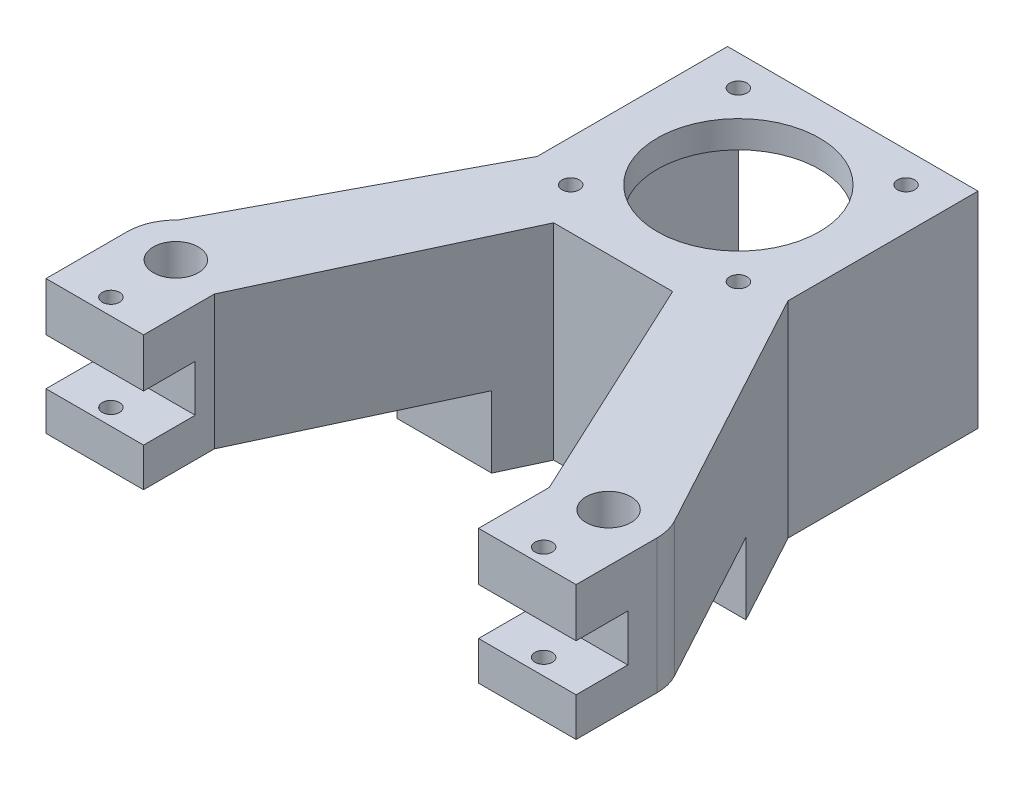
from build123d import *

# Parameters (mm, degrees)
SKETCH_6_W          = 42.3
SKETCH_6_H          = 42.3
SKETCH_6_R          = 1.6
SKETCH_6_R_2        = 15
EXTRUDE_1_DEPTH     = 5
SKETCH_7_R          = 1.6
SKETCH_7_R_2        = 4.15
EXTRUDE_5_DEPTH     = 38
SKETCH_7_7_R        = 4.15
SKETCH_7_7_R_2      = 1.6
EXTRUDE_7_DEPTH     = 38
SKETCH_7_8_R        = 4.15
SKETCH_7_8_R_2      = 1.6
EXTRUDE_8_DEPTH     = 38
SKETCH_12_W         = 2
SKETCH_12_H         = 44.3
EXTRUDE_11_DEPTH    = 38
SKETCH_14_W         = 44.3
SKETCH_14_H         = 2
EXTRUDE_12_DEPTH    = 38
SKETCH_15_W         = 2
SKETCH_15_H         = 42.3
EXTRUDE_13_DEPTH    = 38
CUT_EXTRUDE_1_DEPTH = 13.2
SKETCH_18_W         = 9.549489015
SKETCH_18_H         = 8.643215043
CUT_EXTRUDE_2_DEPTH = 123


with BuildPart() as part:
    # 草图6 → 凸台-拉伸1 (new body)
    with BuildSketch(Plane(origin=(0, 0, 0), x_dir=(1, 0, 0), z_dir=(0, 1, 0))):
        Rectangle(SKETCH_6_W, SKETCH_6_H)
        with Locations(Location((15.5, 15.5, 0), (0, 0, 270))):
            Circle(SKETCH_6_R, mode=Mode.SUBTRACT)
        with Locations(Location((-15.5, 15.5, 0), (0, 0, 270))):
            Circle(SKETCH_6_R, mode=Mode.SUBTRACT)
        with Locations(Location((-15.5, -15.5, 0), (0, 0, 270))):
            Circle(SKETCH_6_R, mode=Mode.SUBTRACT)
        with Locations(Location((15.5, -15.5, 0), (0, 0, 270))):
            Circle(SKETCH_6_R, mode=Mode.SUBTRACT)
        with Locations(Location((0, 0, 0), (0, 0, 270))):
            Circle(SKETCH_6_R_2, mode=Mode.SUBTRACT)
    extrude(amount=EXTRUDE_1_DEPTH)

    # 草图7 → 凸台-拉伸5 (add)
    with BuildSketch(Plane(origin=(0, 5, 0), x_dir=(1, 0, 0), z_dir=(0, 1, 0))):
        with BuildLine():
            Line((49, -79), (49, -64))
            ThreePointArc((49, -64), (48.724429591, -61.789948347), (47.914593709, -59.715235547))
            Line((47.914593709, -59.715235547), (21.15, -10.277072187))
            Line((21.15, -10.277072187), (21.15, -21.15))
            Line((21.15, -21.15), (10.070005019, -21.15))
            Line((10.070005019, -21.15), (30.963898233, -65.919418373))
            Line((30.963898233, -65.919418373), (30.963898233, -79))
            Line((30.963898233, -79), (49, -79))
        make_face()
        with Locations(Location((40, -76, 0), (0, 0, 270))):
            Circle(SKETCH_7_R, mode=Mode.SUBTRACT)
        with Locations(Location((40, -64, 0), (0, 0, 270))):
            Circle(SKETCH_7_R_2, mode=Mode.SUBTRACT)
        with BuildLine():
            Line((-30.963898233, -65.919418373), (-10.070005019, -21.15))
            Line((-10.070005019, -21.15), (-21.15, -21.15))
            Line((-21.15, -21.15), (-21.15, -10.282583808))
            Line((-21.15, -10.282583808), (-46.202269248, -57.478354795))
            ThreePointArc((-46.202269248, -57.478354795), (-48.271046585, -60.45179082), (-49, -64))
            Line((-49, -64), (-49, -79))
            Line((-49, -79), (-30.963898233, -79))
            Line((-30.963898233, -79), (-30.963898233, -65.919418373))
        make_face()
        with Locations(Location((-40, -76, 0), (0, 0, 270))):
            Circle(SKETCH_7_R, mode=Mode.SUBTRACT)
        with Locations(Location((-40, -64, 0), (0, 0, 270))):
            Circle(SKETCH_7_R_2, mode=Mode.SUBTRACT)
    extrude(amount=-EXTRUDE_5_DEPTH)


with BuildPart() as extrude_7_tool:
    # 草图7<7> → 凸台-拉伸7 (new body)
    with BuildSketch(Plane(origin=(0, 5, 0), x_dir=(1, 0, 0), z_dir=(0, 1, 0))):
        with Locations(Location((-40, -64, 0), (0, 0, 270))):
            Circle(SKETCH_7_7_R)
        with Locations(Location((40, -64, 0), (0, 0, 270))):
            Circle(SKETCH_7_7_R)
        with Locations(Location((40, -76, 0), (0, 0, 270))):
            Circle(SKETCH_7_7_R_2)
        with Locations(Location((-40, -76, 0), (0, 0, 270))):
            Circle(SKETCH_7_7_R_2)
    extrude(amount=EXTRUDE_7_DEPTH)


with BuildPart() as part_1:
    add(part.part)


with BuildPart() as part_2:
    # 凸台-拉伸7: joined with extrude_7_tool
    add(part_1.part.fuse(extrude_7_tool.part, tol=0.00001))


with BuildPart() as extrude_7_kept_piece:
    # of the separate pieces the step leaves, the one the design keeps (extrude_7_pieces_kept)
    add(part_2.part.solids().sort_by_distance((-10.070005019, 0, 21.15))[0])


with BuildPart() as extrude_8_tool:
    # 草图7<8> → 凸台-拉伸8 (new body)
    with BuildSketch(Plane(origin=(0, 5, 0), x_dir=(1, 0, 0), z_dir=(0, 1, 0))):
        with Locations(Location((-40, -64, 0), (0, 0, 270))):
            Circle(SKETCH_7_8_R)
        with Locations(Location((40, -64, 0), (0, 0, 270))):
            Circle(SKETCH_7_8_R)
        with Locations(Location((40, -76, 0), (0, 0, 270))):
            Circle(SKETCH_7_8_R_2)
        with Locations(Location((-40, -76, 0), (0, 0, 270))):
            Circle(SKETCH_7_8_R_2)
    extrude(amount=EXTRUDE_8_DEPTH)


with BuildPart() as extrude_7_kept_piece_1:
    add(extrude_7_kept_piece.part)


with BuildPart() as extrude_7_kept_piece_2:
    # 凸台-拉伸8: joined with extrude_8_tool
    add(extrude_7_kept_piece_1.part.fuse(extrude_8_tool.part, tol=0.00001))


with BuildPart() as extrude_8_kept_piece:
    # of the separate pieces the step leaves, the one the design keeps (extrude_8_pieces_kept)
    add(extrude_7_kept_piece_2.part.solids().sort_by_distance((-10.070005019, 0, 21.15))[0])

    # 草图12 → 凸台-拉伸11 (add)
    with BuildSketch(Plane(origin=(0, 5, 0), x_dir=(1, 0, 0), z_dir=(0, 1, 0))):
        with Locations((22.15, -1)):
            Rectangle(SKETCH_12_W, SKETCH_12_H)
    extrude(amount=-EXTRUDE_11_DEPTH)

    # 草图14 → 凸台-拉伸12 (add)
    with BuildSketch(Plane(origin=(0, 5, 0), x_dir=(1, 0, 0), z_dir=(0, 1, 0))):
        with Locations((-1, -22.15)):
            Rectangle(SKETCH_14_W, SKETCH_14_H)
    extrude(amount=-EXTRUDE_12_DEPTH)

    # 草图15 → 凸台-拉伸13 (add)
    with BuildSketch(Plane(origin=(0, 5, 0), x_dir=(1, 0, 0), z_dir=(0, 1, 0))):
        with Locations((-22.15, 0)):
            Rectangle(SKETCH_15_W, SKETCH_15_H)
    extrude(amount=-EXTRUDE_13_DEPTH)

    # 草图17 → 切除-拉伸1 (cut)
    with BuildSketch(Plane.XZ.offset(33)):
        Polygon((62.040525686, 30.953335803), (-8.604799232, 30.953335803), (-61.83718559, 30.953335803), (-61.83718559, 85.06296978), (-8.604799232, 85.06296978), (62.040525686, 85.06296978), align=None)
    extrude(amount=-CUT_EXTRUDE_1_DEPTH, mode=Mode.SUBTRACT)

    # 草图18 → 切除-拉伸2 (cut)
    with BuildSketch(Plane(origin=(49, 0, 0), x_dir=(0, 0, -1), z_dir=(1, 0, 0))):
        with Locations((-74.225255492, -8.321607522)):
            Rectangle(SKETCH_18_W, SKETCH_18_H)
    extrude(amount=-CUT_EXTRUDE_2_DEPTH, mode=Mode.SUBTRACT)


solid = extrude_8_kept_piece.part
